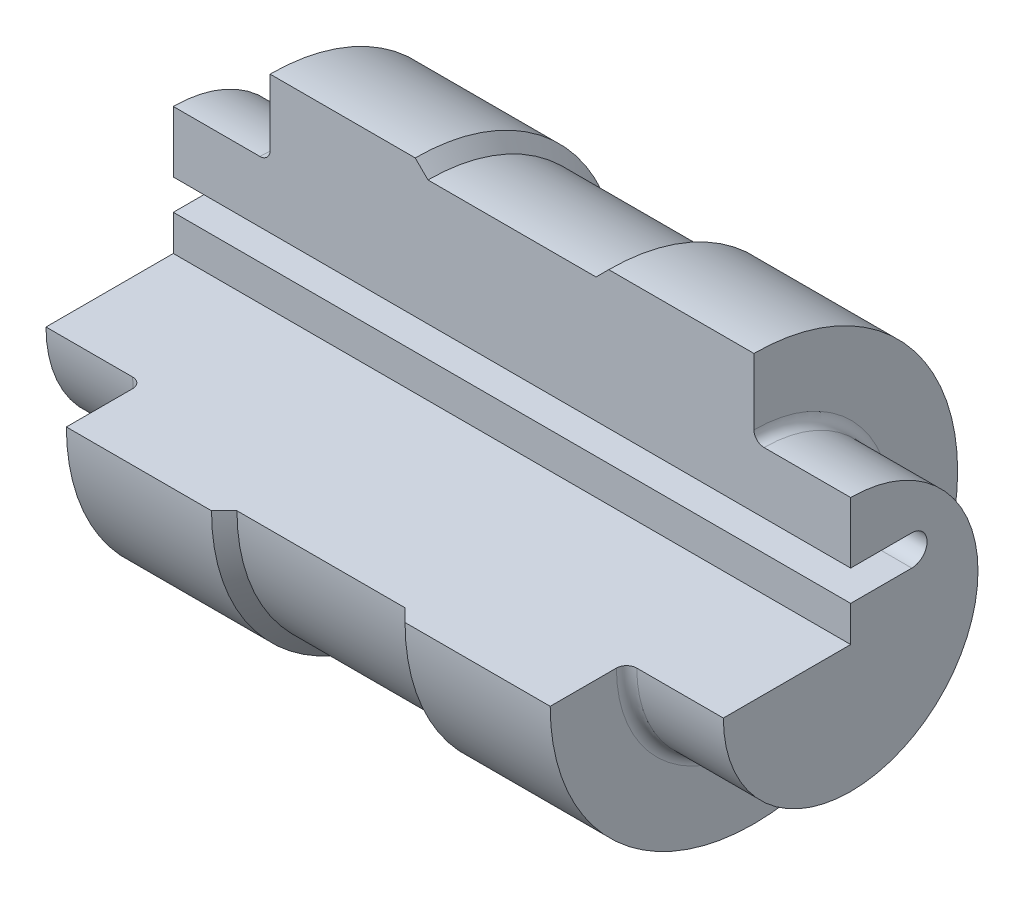
from build123d import *

# Parameters (mm, degrees)
ZAOKR_GLENIE1_R            = 2
WYTNIJ_WYCI_GNI_CIE1_DEPTH = 134


with BuildPart() as part:
    # Szkic2 → Obrót1 (revolve)
    with BuildSketch(Plane.XY):
        Polygon((0, 0), (0, 25), (19, 25), (19, 40), (47.5, 40), (50, 37.5), (83, 37.5), (85.5, 40), (114, 40), (114, 25), (133, 25), (133, 0), align=None)
    revolve(axis=Axis((133, 0, 0), (-1, 0, 0)))

    # Zaokrąglenie1
    zaokr_glenie1_edges = [part.edges().sort_by_distance(p)[0] for p in [
        (114, -25, 0),
        (19, -25, 0),
    ]]
    fillet(zaokr_glenie1_edges, radius=ZAOKR_GLENIE1_R)

    # Szkic3 → Wytnij-wyciągnięcie1 (cut, through all)
    with BuildSketch(Plane.ZY):
        with BuildLine():
            Line((0, 0), (0, 7))
            Line((0, 7), (-12, 7))
            ThreePointArc((-12, 7), (-15, 10), (-12, 13))
            Line((-12, 13), (0, 13))
            Line((0, 13), (0, 40))
            ThreePointArc((0, 40), (28.284271247, 28.284271247), (40, 0))
            Line((40, 0), (0, 0))
        make_face()
    extrude(amount=-WYTNIJ_WYCI_GNI_CIE1_DEPTH, mode=Mode.SUBTRACT)


solid = part.part
